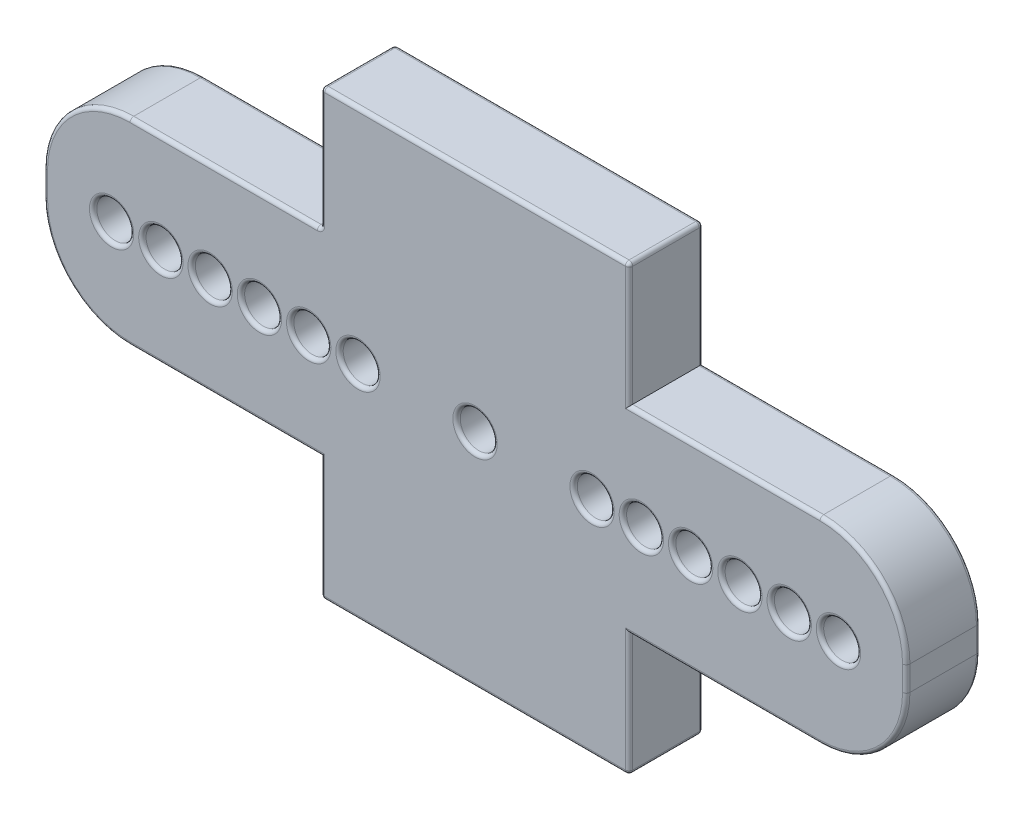
from build123d import *

# Parameters (mm, degrees)
SKETCH1_R           = 0.75
BOSS_EXTRUDE2_DEPTH = 1.5
SKETCH2_R           = 0.75
CUT_EXTRUDE1_DEPTH  = 3
FILLET2_R           = 0.15


with BuildPart() as part:
    # Sketch1 → Boss-Extrude2 (new body, symmetric)
    with BuildSketch(Plane.XY):
        with BuildLine():
            Line((-17.5, 0.5), (-17.5, -0.5))
            ThreePointArc((-17.5, -0.5), (-16.474873734, -2.974873734), (-14, -4))
            Line((-14, -4), (-6.25, -4))
            Line((-6.25, -4), (-6.25, -9))
            Line((-6.25, -9), (6.25, -9))
            Line((6.25, -9), (6.25, -4))
            Line((6.25, -4), (14, -4))
            ThreePointArc((14, -4), (16.474873734, -2.974873734), (17.5, -0.5))
            Line((17.5, -0.5), (17.5, 0.5))
            ThreePointArc((17.5, 0.5), (16.474873734, 2.974873734), (14, 4))
            Line((14, 4), (6.25, 4))
            Line((6.25, 4), (6.25, 9))
            Line((6.25, 9), (-6.25, 9))
            Line((-6.25, 9), (-6.25, 4))
            Line((-6.25, 4), (-14, 4))
            ThreePointArc((-14, 4), (-16.474873734, 2.974873734), (-17.5, 0.5))
        make_face()
        Circle(SKETCH1_R, mode=Mode.SUBTRACT)
    extrude(amount=BOSS_EXTRUDE2_DEPTH, both=True)

    # Sketch2 → Cut-Extrude1 (cut)
    with BuildSketch(Plane.XY.offset(1.5)):
        with Locations((-14.75, 0)):
            Circle(SKETCH2_R)
        with Locations((-12.75, 0)):
            Circle(SKETCH2_R)
        with Locations((-10.75, 0)):
            Circle(SKETCH2_R)
        with Locations((-8.75, 0)):
            Circle(SKETCH2_R)
        with Locations((-6.75, 0)):
            Circle(SKETCH2_R)
        with Locations((-4.75, 0)):
            Circle(SKETCH2_R)
    cut_extrude1 = extrude(amount=-CUT_EXTRUDE1_DEPTH, mode=Mode.SUBTRACT)

    # Mirror1: Cut-Extrude1 across plane
    add(cut_extrude1.mirror(Plane(origin=(0, 0, 0), x_dir=(0, 0, 1), z_dir=(1, 0, 0))), mode=Mode.SUBTRACT)

    # Fillet2
    fillet2_edges = [part.edges().sort_by_distance(p)[0] for p in [
        (-16.474873734, 2.974873734, 1.5),
        (-17.5, 0, 1.5),
        (0, 9, -1.5),
        (6.25, 6.5, -1.5),
        (10.125, 4, -1.5),
        (16.474873734, 2.974873734, -1.5),
        (17.5, 0, -1.5),
        (-16.474873734, -2.974873734, 1.5),
        (16.474873734, -2.974873734, -1.5),
        (10.125, -4, -1.5),
        (6.25, -6.5, -1.5),
        (0, -9, -1.5),
        (-6.25, -6.5, -1.5),
        (-10.125, -4, -1.5),
        (-16.474873734, -2.974873734, -1.5),
        (-17.5, 0, -1.5),
        (-10.125, -4, 1.5),
        (-16.474873734, 2.974873734, -1.5),
        (-10.125, 4, -1.5),
        (-6.25, 6.5, -1.5),
        (-6.25, -6.5, 1.5),
        (0, -9, 1.5),
        (-6.25, 9, 0),
        (6.25, 9, 0),
        (6.25, -9, 0),
        (-6.25, -9, 0),
        (-6.25, 4, 0),
        (6.25, -6.5, 1.5),
        (10.125, -4, 1.5),
        (16.474873734, -2.974873734, 1.5),
        (17.5, 0, 1.5),
        (-0.75, 0, -1.5),
        (-0.75, 0, 1.5),
        (-6.25, 6.5, 1.5),
        (16.474873734, 2.974873734, 1.5),
        (10.125, 4, 1.5),
        (6.25, 6.5, 1.5),
        (0, 9, 1.5),
        (-15.5, 0, 1.5),
        (-15.5, 0, -1.5),
        (-13.5, 0, 1.5),
        (-13.5, 0, -1.5),
        (-11.5, 0, 1.5),
        (-11.5, 0, -1.5),
        (-9.5, 0, 1.5),
        (-9.5, 0, -1.5),
        (-7.5, 0, 1.5),
        (-7.5, 0, -1.5),
        (-5.5, 0, 1.5),
        (-5.5, 0, -1.5),
        (-10.125, 4, 1.5),
        (15.5, 0, 1.5),
        (15.5, 0, -1.5),
        (13.5, 0, 1.5),
        (13.5, 0, -1.5),
        (11.5, 0, 1.5),
        (11.5, 0, -1.5),
        (9.5, 0, 1.5),
        (9.5, 0, -1.5),
        (7.5, 0, 1.5),
        (7.5, 0, -1.5),
        (5.5, 0, 1.5),
        (5.5, 0, -1.5),
    ]]
    fillet(fillet2_edges, radius=FILLET2_R)


solid = part.part
